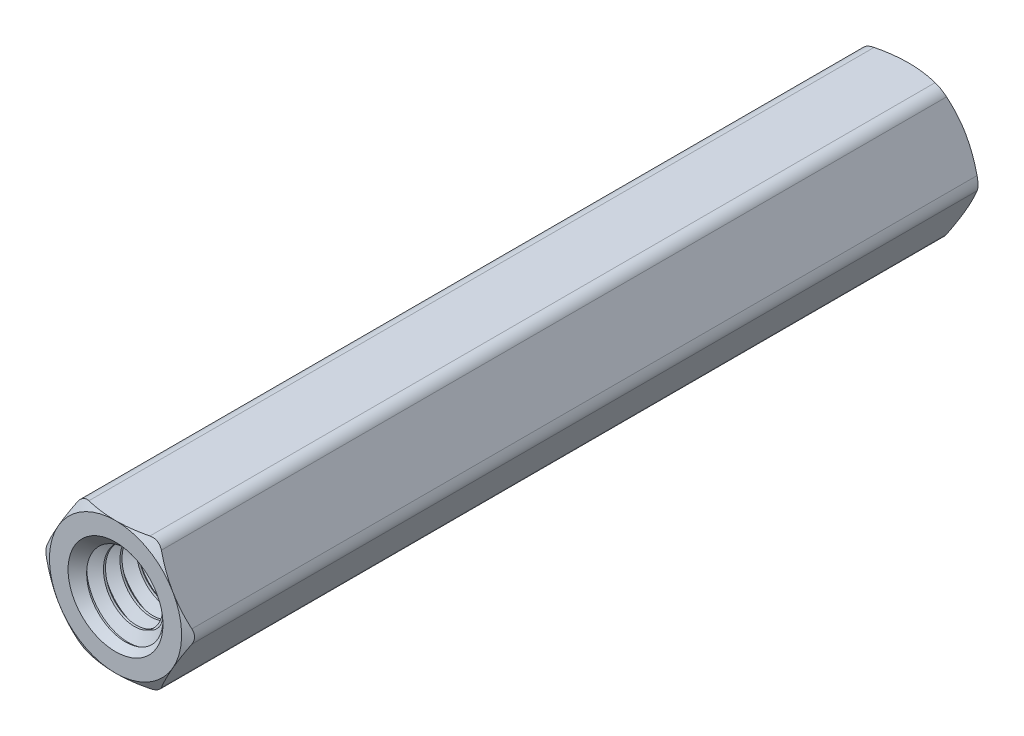
from build123d import *

# Parameters (mm, degrees)
SKETCH4_R              = 2.6289
BOSS_EXTRUDE1_DEPTH    = 19.05
SKETCH5_OUTSIDE_W      = 153.706
SKETCH5_OUTSIDE_H      = 152.724
SKETCH5_OUTSIDE_R      = 3.175
CUT_EXTRUDE1_DEPTH     = 39.407440143
CUT_EXTRUDE1_DRAFT     = -60
SKETCH6_OUTSIDE_W      = 153.706
SKETCH6_OUTSIDE_H      = 152.724
SKETCH6_OUTSIDE_R      = 3.175
CUT_EXTRUDE2_DEPTH     = 39.407440143
CUT_EXTRUDE2_DRAFT     = -60
FILLET1_R              = 0.635
BOSS_EXTRUDE2_START    = -9.525
SKETCH7_R              = 2.2812375
BOSS_EXTRUDE2_DEPTH    = 9.525
SKETCH8_W              = 9.525
SKETCH8_H              = 2.0828
CUT_SWEEP1_PITCH       = 0.79375
CUT_SWEEP1_HEIGHT      = 10.31875
CUT_SWEEP1_RADIUS      = 2.0828
CUT_SWEEP1_START_ANGLE = 90
CIRPATTERN1_COUNT      = 2


with BuildPart() as part:
    # Sketch3 → Revolve1 (revolve)
    with BuildSketch(Plane(origin=(0, 0, 0), x_dir=(0, 0, -1), z_dir=(1, 0, 0))):
        Polygon((-18.8515625, 2.0828), (-9.525, 2.0828), (-9.525, 0), (9.525, 0), (9.525, 2.0828), (19.05, 2.0828), (19.05, 3.175), (0, 3.175), (-19.05, 3.175), (-19.05, 2.2812375), align=None)
        Polygon((-18.8515625, 2.0828), (-9.525, 2.0828), (-9.525, 0), (9.525, 0), (9.525, 2.0828), (19.05, 2.0828), (19.05, 3.175), (0, 3.175), (-19.05, 3.175), (-19.05, 2.2812375), align=None)
    revolve(axis=Axis((0, 0, 9.525), (0, 0, 1)))

    # Sketch4 → Boss-Extrude1 (add, symmetric)
    with BuildSketch(Plane.XY):
        Polygon((-1.833087105, 3.175), (-3.666174209, 0), (-1.833087105, -3.175), (1.833087105, -3.175), (3.666174209, 0), (1.833087105, 3.175), align=None)
        Circle(SKETCH4_R, mode=Mode.SUBTRACT)
    extrude(amount=BOSS_EXTRUDE1_DEPTH, both=True)


with BuildPart() as cut_extrude1_tool:
    # Sketch5 outside → Cut-Extrude1 (with draft: the straight prism first)
    with BuildSketch(Plane.XY.offset(19.05)):
        Rectangle(SKETCH5_OUTSIDE_W, SKETCH5_OUTSIDE_H)
        Circle(SKETCH5_OUTSIDE_R, mode=Mode.SUBTRACT)
    extrude(amount=-CUT_EXTRUDE1_DEPTH)
    # Cut-Extrude1: the draft: its side faces are tilted about the plane it starts from
    cut_extrude1_sides = [cut_extrude1_tool.faces().sort_by_distance(p)[0] for p in [
        (0, -76.362, -0.653720071),
        (76.853, 0, -0.653720071),
        (0, 76.362, -0.653720071),
        (-76.853, 0, -0.653720071),
        (-3.175, 0, -0.653720071),
    ]]
    draft(cut_extrude1_sides, Plane.XY.offset(19.05), CUT_EXTRUDE1_DRAFT)


with BuildPart() as part_1:
    add(part.part)

    # Cut-Extrude1: cut by cut_extrude1_tool
    add(cut_extrude1_tool.part, mode=Mode.SUBTRACT)


with BuildPart() as cut_extrude2_tool:
    # Sketch6 outside → Cut-Extrude2 (with draft: the straight prism first)
    with BuildSketch(Plane(origin=(0, 0, -19.05), x_dir=(-1, 0, 0), z_dir=(0, 0, -1))):
        Rectangle(SKETCH6_OUTSIDE_W, SKETCH6_OUTSIDE_H)
        Circle(SKETCH6_OUTSIDE_R, mode=Mode.SUBTRACT)
    extrude(amount=-CUT_EXTRUDE2_DEPTH)
    # Cut-Extrude2: the draft: its side faces are tilted about the plane it starts from
    cut_extrude2_sides = [cut_extrude2_tool.faces().sort_by_distance(p)[0] for p in [
        (0, -76.362, 0.653720071),
        (-76.853, 0, 0.653720071),
        (0, 76.362, 0.653720071),
        (76.853, 0, 0.653720071),
        (3.175, 0, 0.653720071),
    ]]
    draft(cut_extrude2_sides, Plane(origin=(0, 0, -19.05), x_dir=(-1, 0, 0), z_dir=(0, 0, -1)), CUT_EXTRUDE2_DRAFT)


with BuildPart() as part_2:
    add(part_1.part)

    # Cut-Extrude2: cut by cut_extrude2_tool
    add(cut_extrude2_tool.part, mode=Mode.SUBTRACT)

    # Fillet1
    fillet1_edges = [part_2.edges().sort_by_distance(p)[0] for p in [
        (1.833087105, 3.175, 0),
        (-3.666174209, 0, 0),
        (-1.833087105, -3.175, 0),
        (1.833087105, -3.175, 0),
        (3.666174209, 0, 0),
        (-1.833087105, 3.175, 0),
    ]]
    fillet(fillet1_edges, radius=FILLET1_R)

    # Split1
    split(bisect_by=Plane.XY, keep=Keep.TOP)

    # Sketch7 → Boss-Extrude2 (add)
    with BuildSketch(Plane(origin=(0, 0, 9.525), x_dir=(-1, 0, 0), z_dir=(0, 0, -1)).offset(BOSS_EXTRUDE2_START)):
        Circle(SKETCH7_R)
    extrude(amount=BOSS_EXTRUDE2_DEPTH)


with BuildPart() as body_2:
    # Sketch8 → Revolve2 (revolve)
    with BuildSketch(Plane(origin=(0, 0, 0), x_dir=(0, 0, -1), z_dir=(1, 0, 0))):
        with Locations((-14.2875, 1.0414)):
            Rectangle(SKETCH8_W, SKETCH8_H)
    revolve(axis=Axis((0, 0, 9.525), (0, 0, 1)))

    # Cut-Sweep1: sweep along a helix
    with BuildLine() as cut_sweep1_path:
        add(Helix(CUT_SWEEP1_PITCH, CUT_SWEEP1_HEIGHT, CUT_SWEEP1_RADIUS, center=(0, 0, 19.05), direction=(0, 0, -1), mode=Mode.PRIVATE).rotate(Axis((0, 0, 19.05), (0, 0, -1)), CUT_SWEEP1_START_ANGLE))
    # Sketch10 → Cut-Sweep1 (sweep, cut)
    with BuildSketch(Plane(origin=(0, 0, 0), x_dir=(0, 0, -1), z_dir=(1, 0, 0))):
        Polygon((-19.446875, 1.567244252), (-19.34765625, 1.567244252), (-19.025195312, 2.125762979), (-19.769335937, 2.125762979), align=None)
    sweep(path=cut_sweep1_path.line, is_frenet=True, mode=Mode.SUBTRACT)


with BuildPart() as part_3:
    add(part_2.part)

    # Combine1: cut body 2
    add(body_2.part, mode=Mode.SUBTRACT)

    # Cut-Extrude3 cone 1 section (through the dimple's axis) → Cut-Extrude3 (revolve, cut)
    with BuildSketch(Plane(origin=(0, 0, 19.05), x_dir=(0, -1, 0), z_dir=(1, 0, 0))):
        Polygon((0, 0), (2.2812375, 0), (0, 2.2812375), align=None)
    revolve(axis=Axis((0, 0, 19.05), (0, 0, -1)), mode=Mode.SUBTRACT)


with BuildPart() as cirpattern1_1:
    # CirPattern1: pattern copy
    add(part_3.part.rotate(Axis((0, 0, 0), (1, 0, 0)), 1 * 360 / CIRPATTERN1_COUNT))


with BuildPart() as part_4:
    add(part_3.part)

    # Combine2: union CirPattern1_1
    add(cirpattern1_1.part)


solid = part_4.part
